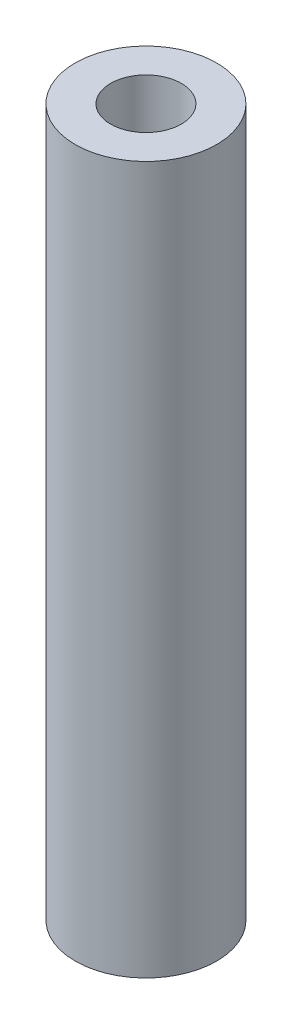
from build123d import *

# Parameters (mm, degrees)
CROQUIS1_R              = 0.5
CROQUIS1_R_2            = 0.25
SALIENTE_EXTRUIR1_DEPTH = 5


with BuildPart() as part:
    # Croquis1 → Saliente-Extruir1 (new body)
    with BuildSketch(Plane(origin=(0, 0, 0), x_dir=(1, 0, 0), z_dir=(0, 1, 0))):
        Circle(CROQUIS1_R)
        Circle(CROQUIS1_R_2, mode=Mode.SUBTRACT)
    extrude(amount=SALIENTE_EXTRUIR1_DEPTH)


solid = part.part
